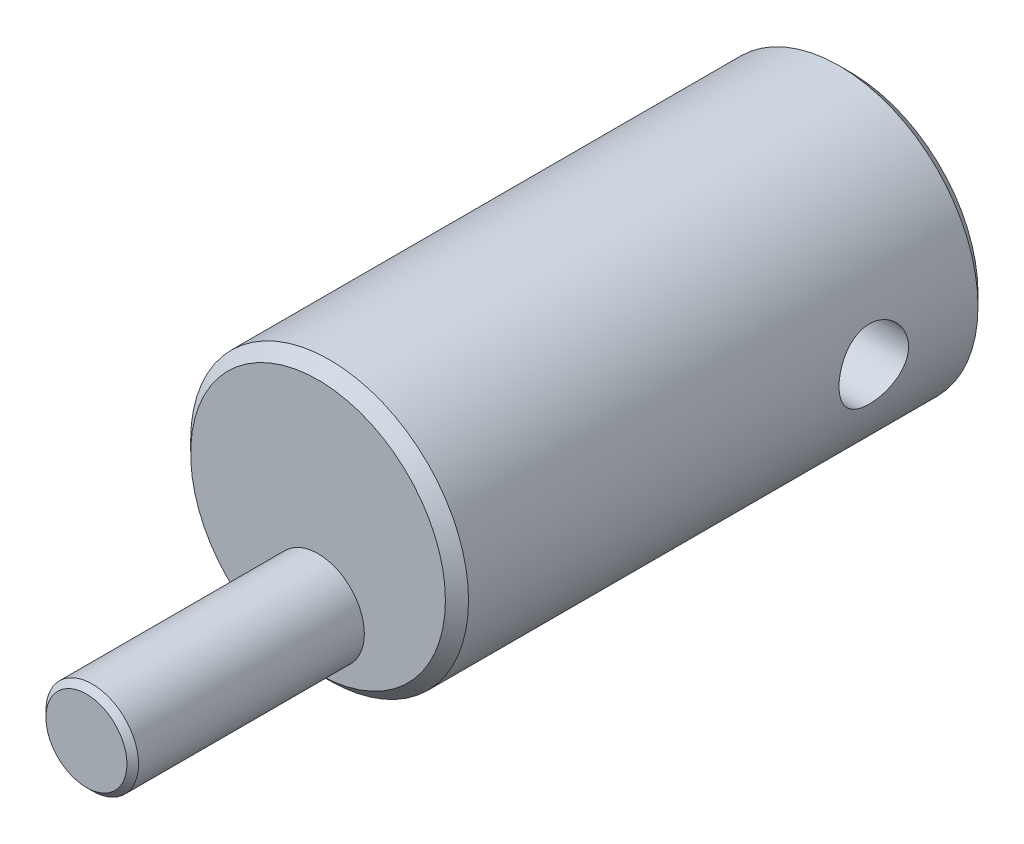
from build123d import *

# Parameters (mm, degrees)
SKETCH1_R               = 6
BOSS_EXTRUDE1_DEPTH     = 23
SKETCH2_R               = 2
BOSS_EXTRUDE2_DEPTH     = 10
CHAMFER1_SIZE           = 0.5
CHAMFER2_SIZE           = 0.25
SKETCH3_R               = 1.5
CUT_EXTRUDE1_DEPTH      = 7
CUT_EXTRUDE1_DEPTH_BACK = 7


with BuildPart() as part:
    # Sketch1 → Boss-Extrude1 (new body)
    with BuildSketch(Plane.XY):
        Circle(SKETCH1_R)
    extrude(amount=BOSS_EXTRUDE1_DEPTH)

    # Sketch2 → Boss-Extrude2 (add)
    with BuildSketch(Plane.XY.offset(23)):
        with Locations((0, -3)):
            Circle(SKETCH2_R)
    extrude(amount=BOSS_EXTRUDE2_DEPTH)

    # Chamfer1
    chamfer1_edges = [part.edges().sort_by_distance(p)[0] for p in [
        (-6, 0, 0),
        (-6, 0, 23),
    ]]
    chamfer(chamfer1_edges, length=CHAMFER1_SIZE)

    # Chamfer2
    chamfer2_edges = [part.edges().sort_by_distance(p)[0] for p in [
        (-2, -3, 33),
    ]]
    chamfer(chamfer2_edges, length=CHAMFER2_SIZE)

    # Sketch3 → Cut-Extrude1 (cut, two sides)
    with BuildSketch(Plane(origin=(0, 0, 0), x_dir=(0, 0, -1), z_dir=(1, 0, 0))) as cut_extrude1_sk:
        with Locations((-5, 0)):
            Circle(SKETCH3_R)
    extrude(amount=CUT_EXTRUDE1_DEPTH, mode=Mode.SUBTRACT)
    extrude(cut_extrude1_sk.sketch, amount=-CUT_EXTRUDE1_DEPTH_BACK, mode=Mode.SUBTRACT)


solid = part.part
